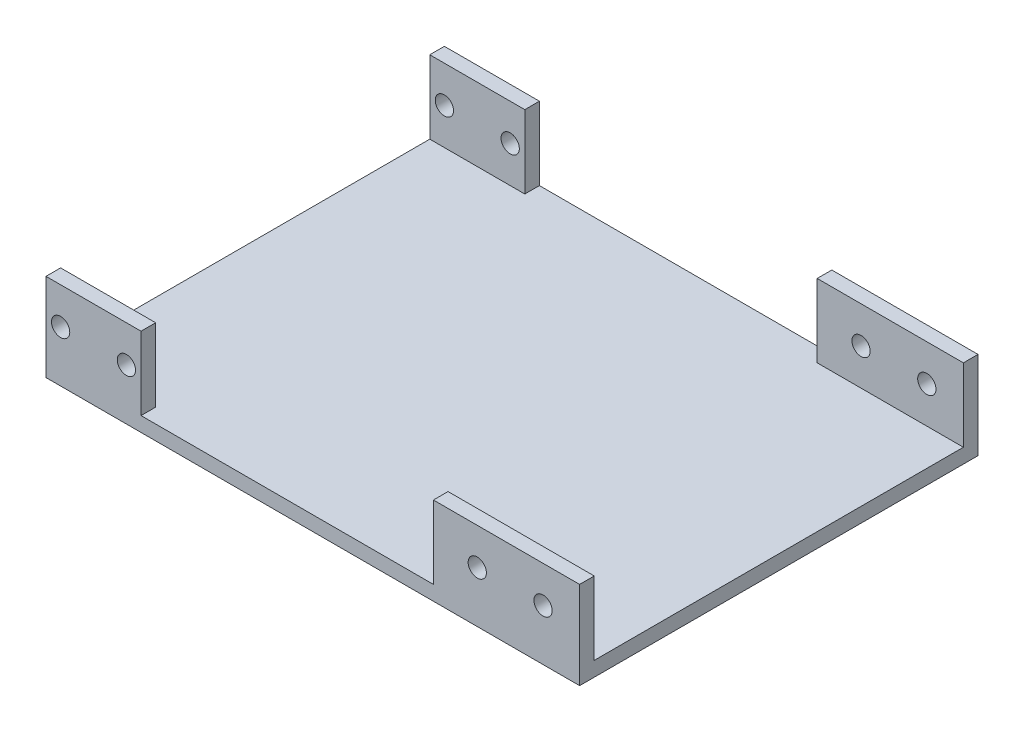
from build123d import *

# Parameters (mm, degrees)
SKETCH1_W           = 73
SKETCH1_H           = 54.5
BOSS_EXTRUDE1_DEPTH = 2
SKETCH2_W           = 20
SKETCH2_H           = 2
SKETCH2_W_2         = 13
BOSS_EXTRUDE2_DEPTH = 10
SKETCH3_R           = 1.25
CUT_EXTRUDE1_DEPTH  = 55.5


with BuildPart() as part:
    # Sketch1 → Boss-Extrude1 (new body)
    with BuildSketch(Plane(origin=(0, 0, 0), x_dir=(1, 0, 0), z_dir=(0, 1, 0))):
        with Locations((-15.498549405, 1.944031796)):
            Rectangle(SKETCH1_W, SKETCH1_H)
    extrude(amount=BOSS_EXTRUDE1_DEPTH)

    # Sketch2 → Boss-Extrude2 (add)
    with BuildSketch(Plane(origin=(0, 2, 0), x_dir=(1, 0, 0), z_dir=(0, 1, 0))):
        with Locations((11.001450595, 28.194031796)):
            Rectangle(SKETCH2_W, SKETCH2_H)
        with Locations((11.001450595, -24.305968204)):
            Rectangle(SKETCH2_W, SKETCH2_H)
        with Locations((-45.498549405, 28.194031796)):
            Rectangle(SKETCH2_W_2, SKETCH2_H)
        with Locations((-45.498549405, -24.305968204)):
            Rectangle(SKETCH2_W_2, SKETCH2_H)
    extrude(amount=BOSS_EXTRUDE2_DEPTH)

    # Sketch3 → Cut-Extrude1 (cut, through all)
    with BuildSketch(Plane.XY.offset(25.305968204)):
        with Locations((16.001450595, 7)):
            Circle(SKETCH3_R)
        with Locations((7.001450595, 7)):
            Circle(SKETCH3_R)
        with Locations((-40.998549405, 7)):
            Circle(SKETCH3_R)
        with Locations((-49.998549405, 7)):
            Circle(SKETCH3_R)
    extrude(amount=-CUT_EXTRUDE1_DEPTH, mode=Mode.SUBTRACT)


solid = part.part
